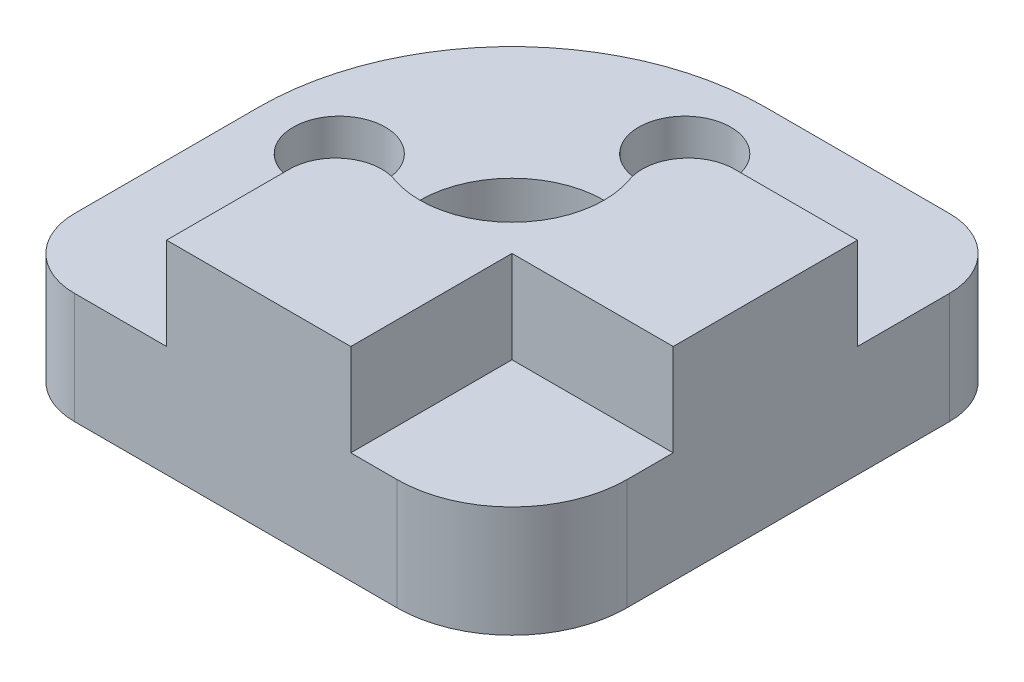
from build123d import *

# Parameters (mm, degrees)
SKETCH1_R           = 4
SKETCH1_R_2         = 2
BOSS_EXTRUDE1_DEPTH = 4.825
BOSS_EXTRUDE2_DEPTH = 4


with BuildPart() as part:
    # Sketch1 → Boss-Extrude1 (new body)
    with BuildSketch(Plane(origin=(0, 0, 0), x_dir=(1, 0, 0), z_dir=(0, 1, 0))):
        with BuildLine():
            Line((-11, 0), (-11, -8))
            ThreePointArc((-11, -8), (-10.121320344, -10.121320344), (-8, -11))
            Line((-8, -11), (6, -11))
            ThreePointArc((6, -11), (9.535533906, -9.535533906), (11, -6))
            Line((11, -6), (11, 8))
            ThreePointArc((11, 8), (10.121320344, 10.121320344), (8, 11))
            Line((8, 11), (0, 11))
            ThreePointArc((0, 11), (-7.778174593, 7.778174593), (-11, 0))
        make_face()
        with Locations(Location((0, 0, 0), (0, 0, 270))):  # turned: the seam where the file's is
            Circle(SKETCH1_R, mode=Mode.SUBTRACT)
        with Locations(Location((-7.5, 0, 0), (0, 0, 270))):  # turned: the seam where the file's is
            Circle(SKETCH1_R_2, mode=Mode.SUBTRACT)
        with Locations(Location((0, 7.5, 0), (0, 0, 270))):  # turned: the seam where the file's is
            Circle(SKETCH1_R_2, mode=Mode.SUBTRACT)
    extrude(amount=BOSS_EXTRUDE1_DEPTH)

    # Sketch2 → Boss-Extrude2 (add)
    with BuildSketch(Plane(origin=(0, 4.825, 0), x_dir=(1, 0, 0), z_dir=(0, 1, 0))):
        with BuildLine():
            Line((4, -11), (4, -4))
            Line((4, -4), (11, -4))
            Line((11, -4), (11, 4))
            Line((11, 4), (5.656854249, 4))
            ThreePointArc((5.656854249, 4), (4.023861088, 3.154700538), (3.771236166, 1.333333333))
            ThreePointArc((3.771236166, 1.333333333), (2.828427125, -2.828427125), (-1.333333333, -3.771236166))
            ThreePointArc((-1.333333333, -3.771236166), (-3.154700538, -4.023861088), (-4, -5.656854249))
            Line((-4, -5.656854249), (-4, -11))
            Line((-4, -11), (4, -11))
        make_face()
    extrude(amount=BOSS_EXTRUDE2_DEPTH)


solid = part.part
